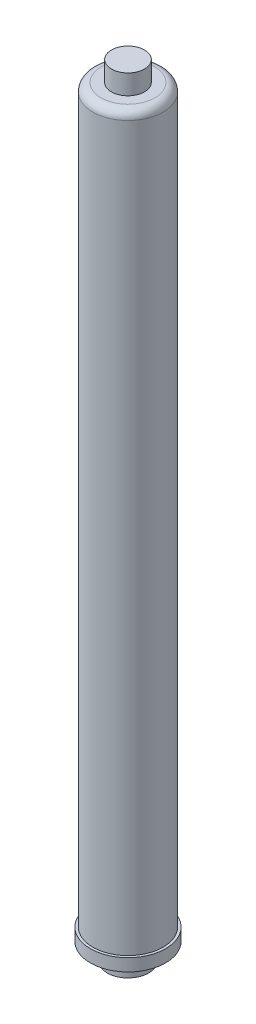
from build123d import *


with BuildPart() as part:
    # Sketch1 → Revolve1 (revolve)
    with BuildSketch(Plane.XY):
        with BuildLine():
            Line((14.605, -22.733), (15.875, -22.733))
            Line((15.875, -22.733), (15.875, -9.525))
            Line((15.875, -9.525), (28.8925, -9.525))
            Line((28.8925, -9.525), (28.8925, 0))
            Line((28.8925, 0), (26.9875, 0))
            Line((26.9875, 0), (26.9875, 556.006))
            ThreePointArc((26.9875, 556.006), (25.127628061, 560.496128061), (20.6375, 562.356))
            Line((20.6375, 562.356), (12.7, 562.356))
            Line((12.7, 562.356), (12.7, 577.596))
            Line((12.7, 577.596), (0, 577.596))
            Line((0, 577.596), (0, 28.067))
            Line((0, 28.067), (14.605, -22.733))
        make_face()
    revolve(axis=Axis((0, 577.596, 0), (0, -1, 0)))


solid = part.part
